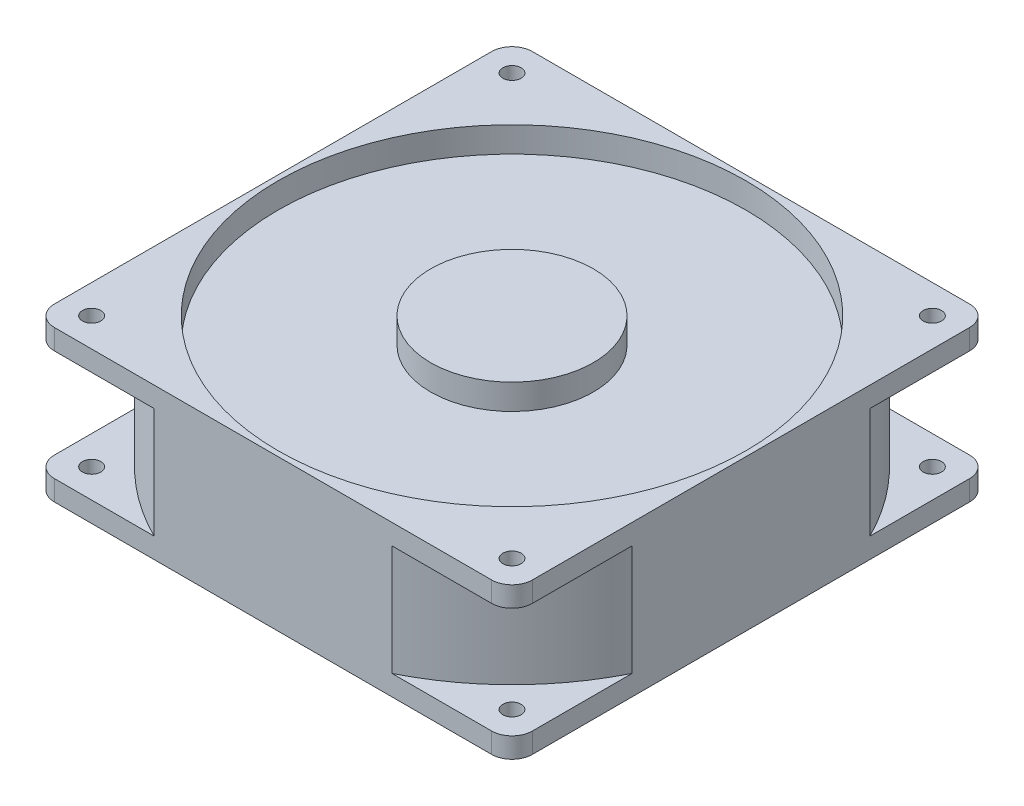
from build123d import *

# Parameters (mm, degrees)
SKETCH1_W           = 119.38
SKETCH1_H           = 119.38
BOSS_EXTRUDE1_DEPTH = 37.75
SKETCH2_R           = 2.286
CUT_EXTRUDE1_DEPTH  = 38.75
SKETCH3_R           = 58.41973455
CUT_EXTRUDE2_DEPTH  = 6.35
SKETCH4_R           = 58.42
CUT_EXTRUDE3_DEPTH  = 6.35
SKETCH5_R           = 20.32
BOSS_EXTRUDE2_DEPTH = 6.35
SKETCH6_R           = 20.32
BOSS_EXTRUDE3_DEPTH = 6.35
FILLET1_R           = 5.08
SKETCH7_R           = 88.9
SKETCH7_R_2         = 66.675
CUT_EXTRUDE5_DEPTH  = 13.8


with BuildPart() as part:
    # Sketch1 → Boss-Extrude1 (new body)
    with BuildSketch(Plane(origin=(0, 0, 0), x_dir=(1, 0, 0), z_dir=(0, 1, 0))):
        with Locations((-57.011822664, 51.361162791)):
            Rectangle(SKETCH1_W, SKETCH1_H)
    extrude(amount=BOSS_EXTRUDE1_DEPTH)

    # Sketch2 → Cut-Extrude1 (cut, through all)
    with BuildSketch(Plane(origin=(0, 37.75, 0), x_dir=(1, 0, 0), z_dir=(0, 1, 0))):
        with Locations((-109.511822664, 103.861162791)):
            Circle(SKETCH2_R)
        with Locations((-4.511822664, 103.861162791)):
            Circle(SKETCH2_R)
        with Locations((-4.511822664, -1.138837209)):
            Circle(SKETCH2_R)
        with Locations((-109.511822664, -1.138837209)):
            Circle(SKETCH2_R)
    extrude(amount=-CUT_EXTRUDE1_DEPTH, mode=Mode.SUBTRACT)

    # Sketch3 → Cut-Extrude2 (cut)
    with BuildSketch(Plane(origin=(0, 37.75, 0), x_dir=(1, 0, 0), z_dir=(0, 1, 0))):
        with Locations((-57.011822664, 51.361162791)):
            Circle(SKETCH3_R)
    extrude(amount=-CUT_EXTRUDE2_DEPTH, mode=Mode.SUBTRACT)

    # Sketch4 → Cut-Extrude3 (cut)
    with BuildSketch(Plane.XZ):
        with Locations((-57.011822664, -51.361162791)):
            Circle(SKETCH4_R)
    extrude(amount=-CUT_EXTRUDE3_DEPTH, mode=Mode.SUBTRACT)

    # Sketch5 → Boss-Extrude2 (add)
    with BuildSketch(Plane.XZ.offset(-6.35)):
        with Locations((-57.011822664, -51.361162791)):
            Circle(SKETCH5_R)
    extrude(amount=BOSS_EXTRUDE2_DEPTH)

    # Sketch6 → Boss-Extrude3 (add)
    with BuildSketch(Plane(origin=(0, 31.4, 0), x_dir=(1, 0, 0), z_dir=(0, 1, 0))):
        with Locations((-57.011822664, 51.361162791)):
            Circle(SKETCH6_R)
    extrude(amount=BOSS_EXTRUDE3_DEPTH)

    # Fillet1
    fillet1_edges = [part.edges().sort_by_distance(p)[0] for p in [
        (2.678177336, 18.875, 8.328837209),
        (-116.701822664, 18.875, 8.328837209),
        (-116.701822664, 18.875, -111.051162791),
        (2.678177336, 18.875, -111.051162791),
    ]]
    fillet(fillet1_edges, radius=FILLET1_R)

    # Sketch7 → Cut-Extrude5 (cut, symmetric)
    with BuildSketch(Plane(origin=(0, 18.875, 0), x_dir=(1, 0, 0), z_dir=(0, 1, 0))):
        with Locations((-57.011822664, 51.361162791)):
            Circle(SKETCH7_R)
        with Locations((-57.011822664, 51.361162791)):
            Circle(SKETCH7_R_2, mode=Mode.SUBTRACT)
    extrude(amount=CUT_EXTRUDE5_DEPTH, both=True, mode=Mode.SUBTRACT)


solid = part.part
